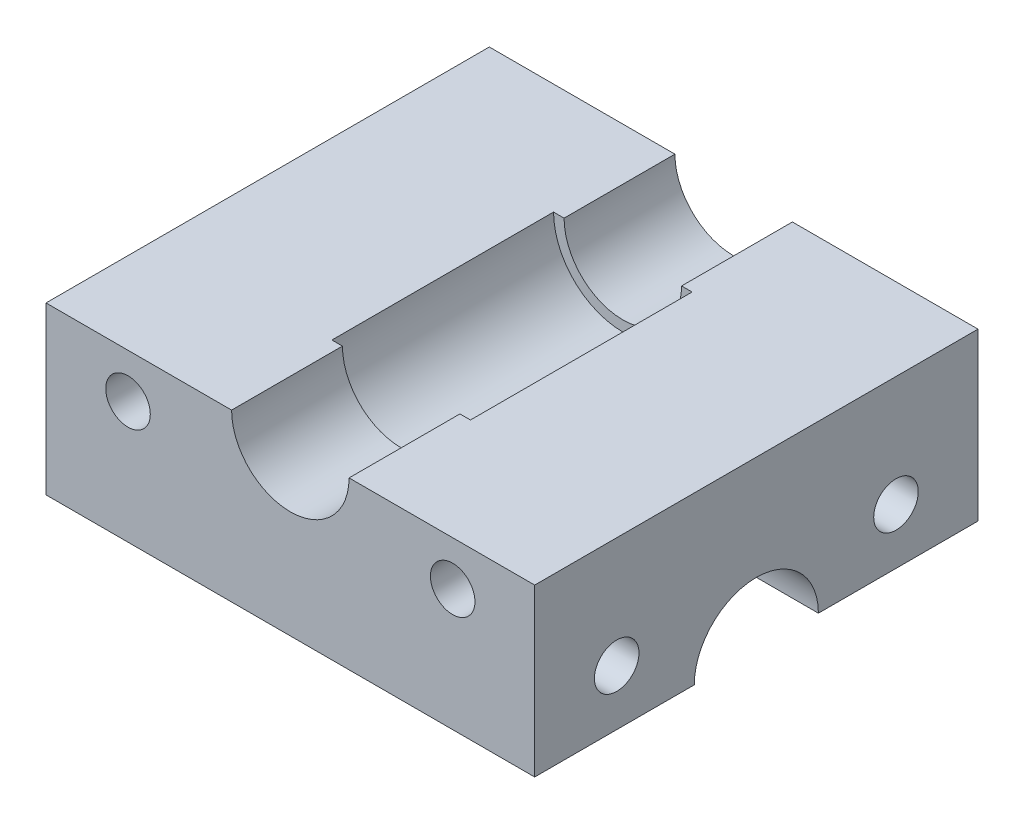
from build123d import *

# Parameters (mm, degrees)
BOSS_EXTRUDE1_DEPTH              = 50.8
SKETCH2_R                        = 7.9375
CUT_EXTRUDE1_DEPTH               = 12.7
F_10_CLEARANCE_HOLE1_D           = 5.1054
F_10_CLEARANCE_HOLE1_ON_FACE_2_D = 5.1054
CUT_EXTRUDE4_DEPTH               = 57


with BuildPart() as part:
    # Sketch1 → Boss-Extrude1 (new body)
    with BuildSketch(Plane.XY):
        with BuildLine():
            Line((23.736970149, 16.573322883), (45.005970149, 16.573322883))
            Line((45.005970149, 16.573322883), (45.005970149, -2.476677117))
            Line((45.005970149, -2.476677117), (-10.994029851, -2.476677117))
            Line((-10.994029851, -2.476677117), (-10.994029851, 16.573322883))
            Line((-10.994029851, 16.573322883), (10.274970149, 16.573322883))
            ThreePointArc((10.274970149, 16.573322883), (17.005970149, 9.842322883), (23.736970149, 16.573322883))
        make_face()
    extrude(amount=BOSS_EXTRUDE1_DEPTH)

    # Sketch2 → Cut-Extrude1 (cut, symmetric)
    with BuildSketch(Plane.XY.offset(25.4)):
        with Locations((17.005970149, 16.573322883)):
            Circle(SKETCH2_R)
    extrude(amount=CUT_EXTRUDE1_DEPTH, both=True, mode=Mode.SUBTRACT)

    # #10 Clearance Hole1 (through all)
    with Locations(Plane(origin=(-10.994029851, 3.873322883, 41.402), x_dir=(0, 0, -1), z_dir=(-1, 0, 0))):
        with Locations((0, 0), (32.004, 0)):
            Hole(F_10_CLEARANCE_HOLE1_D / 2)

    # #10 Clearance Hole1 on face 2 (through all)
    with Locations(Plane(origin=(-1.596029851, 11.493322883, 50.8), x_dir=(1, 0, 0), z_dir=(0, 0, 1))):
        with Locations((0, 0), (37.204, 0)):
            Hole(F_10_CLEARANCE_HOLE1_ON_FACE_2_D / 2)

    # Sketch9 → Cut-Extrude4 (cut, through all)
    with BuildSketch(Plane(origin=(45.005970149, 0, 0), x_dir=(0, 0, -1), z_dir=(1, 0, 0))):
        with BuildLine():
            Line((-32.512, -2.476677117), (-18.288, -2.476677117))
            ThreePointArc((-18.288, -2.476677117), (-25.4, 4.635322883), (-32.512, -2.476677117))
        make_face()
    extrude(amount=-CUT_EXTRUDE4_DEPTH, mode=Mode.SUBTRACT)


solid = part.part
